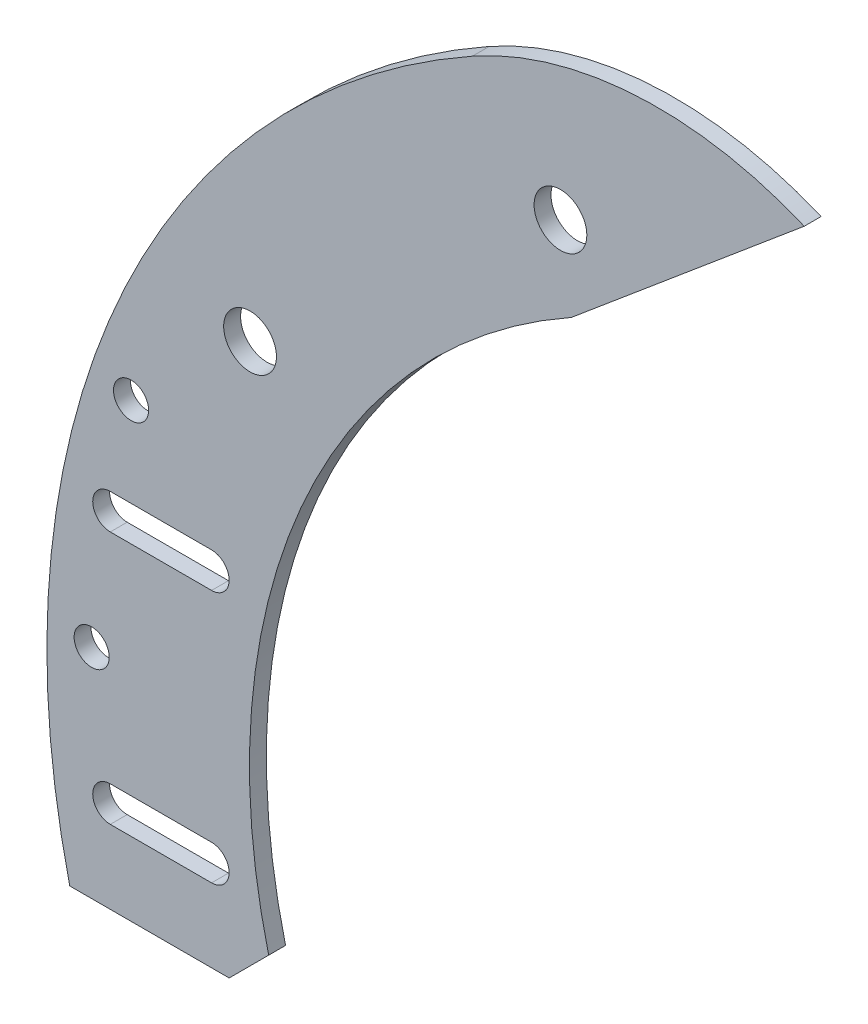
from build123d import *

# Parameters (mm, degrees)
BOSS_EXTRUDE1_DEPTH              = 3.175
CUT_EXTRUDE1_DEPTH               = 3.175
SKETCH4_R                        = 3.302
CUT_EXTRUDE2_DEPTH               = 3.175
F_25_64_0_39063_DIAMETER_HOLE1_D = 9.922002


with BuildPart() as part:
    # Sketch1 → Boss-Extrude1 (new body)
    with BuildSketch(Plane.XY):
        with BuildLine():
            Line((-153.9561854, -36.5125), (-123.978950074, -36.5125))
            Line((-123.978950074, -36.5125), (-116.548747531, -29.082297457))
            ThreePointArc((-116.548747531, -29.082297457), (-110.518418653, 46.73895163), (-59.613700036, 103.253872686))
            Line((-59.613700036, 103.253872686), (-15.834260112, 139.989184579))
            ThreePointArc((-15.834260112, 139.989184579), (-47.43896166, 145.45922618), (-78.234917279, 136.493311135))
            ThreePointArc((-78.234917279, 136.493311135), (-145.12613966, 62.696527677), (-153.9561854, -36.5125))
        make_face()
    extrude(amount=BOSS_EXTRUDE1_DEPTH)

    # Sketch2 → Cut-Extrude1 (cut)
    with BuildSketch(Plane.XY.offset(3.175)):
        with BuildLine():
            Line((-146.3361854, -16.0655), (-127.2861854, -16.0655))
            ThreePointArc((-127.2861854, -16.0655), (-123.9841854, -19.3675), (-127.2861854, -22.6695))
            Line((-127.2861854, -22.6695), (-146.3361854, -22.6695))
            ThreePointArc((-146.3361854, -22.6695), (-149.6381854, -19.3675), (-146.3361854, -16.0655))
        make_face()
        with BuildLine():
            Line((-146.3361854, 31.5595), (-127.2861854, 31.5595))
            ThreePointArc((-127.2861854, 31.5595), (-123.9841854, 28.2575), (-127.2861854, 24.9555))
            Line((-127.2861854, 24.9555), (-146.3361854, 24.9555))
            ThreePointArc((-146.3361854, 24.9555), (-149.6381854, 28.2575), (-146.3361854, 31.5595))
        make_face()
    extrude(amount=-CUT_EXTRUDE1_DEPTH, mode=Mode.SUBTRACT)

    # Sketch4 → Cut-Extrude2 (cut)
    with BuildSketch(Plane.XY.offset(3.175)):
        with Locations((-149.837364131, 4.445)):
            Circle(SKETCH4_R)
        with Locations((-142.427155303, 48.347866959)):
            Circle(SKETCH4_R)
    extrude(amount=-CUT_EXTRUDE2_DEPTH, mode=Mode.SUBTRACT)

    # 25_64 _0.39063_ Diameter Hole1 (through all)
    with Locations(Plane.XY.offset(3.175)):
        with Locations((-120.049591928, 69.120810664), (-61.677005362, 118.101226522)):
            Hole(F_25_64_0_39063_DIAMETER_HOLE1_D / 2)


solid = part.part
